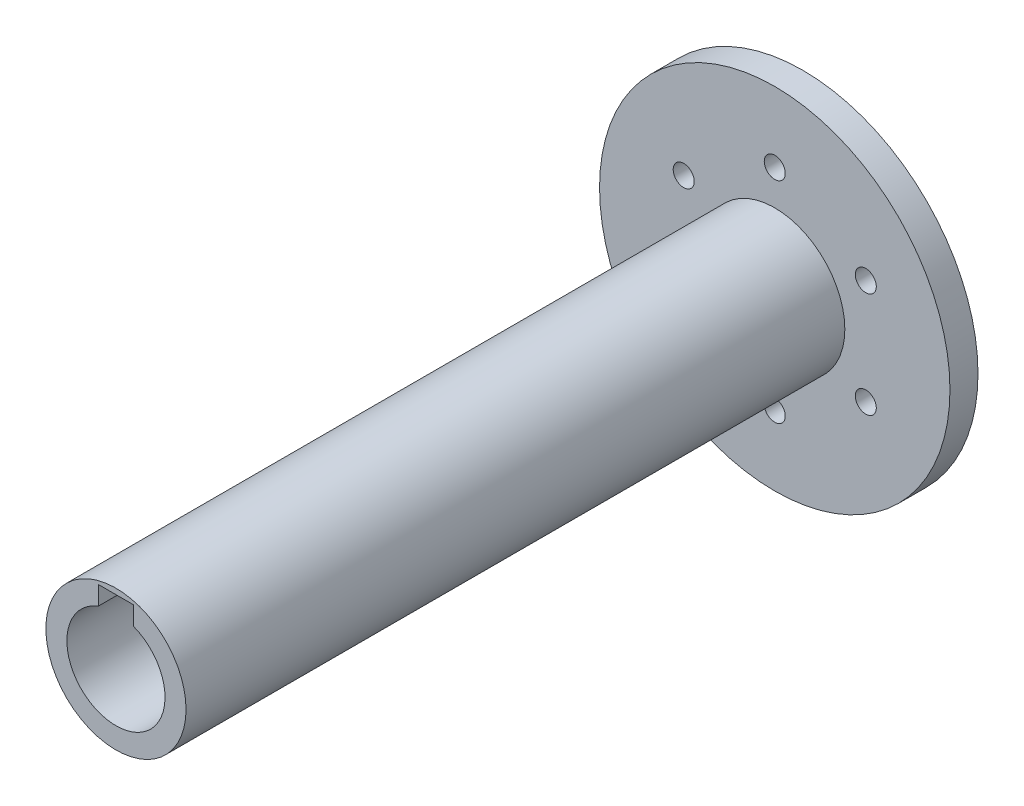
from build123d import *

# Parameters (mm, degrees)
SKETCH_1_R          = 10
EXTRUDE_1_DEPTH     = 94
CUT_EXTRUDE_1_DEPTH = 30
SKETCH_3_R          = 1.5
CUT_EXTRUDE_2_DEPTH = 95
SKETCH_4_R          = 25
SKETCH_4_R_2        = 1.5
EXTRUDE_2_DEPTH     = 4
SKETCH_5_R          = 1.5
CUT_EXTRUDE_5_DEPTH = 4


with BuildPart() as part:
    # 草图1 → 凸台-拉伸1 (new body)
    with BuildSketch(Plane.XY):
        Circle(SKETCH_1_R)
    extrude(amount=EXTRUDE_1_DEPTH)

    # 草图2 → 切除-拉伸1 (cut)
    with BuildSketch(Plane.XY.offset(94)):
        with BuildLine():
            Line((-2.5, 6.538348415), (-2.5, 9.2))
            Line((-2.5, 9.2), (2.5, 9.2))
            Line((2.5, 9.2), (2.5, 6.538348415))
            ThreePointArc((2.5, 6.538348415), (0, -7), (-2.5, 6.538348415))
        make_face()
    extrude(amount=-CUT_EXTRUDE_1_DEPTH, mode=Mode.SUBTRACT)

    # 草图3 → 切除-拉伸2 (cut, through all)
    with BuildSketch(Plane(origin=(0, 0, 0), x_dir=(-1, 0, 0), z_dir=(0, 0, -1))):
        Circle(SKETCH_3_R)
    extrude(amount=-CUT_EXTRUDE_2_DEPTH, mode=Mode.SUBTRACT)

    # 草图4 → 凸台-拉伸2 (add)
    with BuildSketch(Plane(origin=(0, 0, 0), x_dir=(-1, 0, 0), z_dir=(0, 0, -1))):
        Circle(SKETCH_4_R)
        Circle(SKETCH_4_R_2, mode=Mode.SUBTRACT)
    extrude(amount=EXTRUDE_2_DEPTH)

    # 草图5 → 切除-拉伸5 (cut)
    with BuildSketch(Plane(origin=(0, 0, -4), x_dir=(-1, 0, 0), z_dir=(0, 0, -1))):
        with Locations((0, 15)):
            Circle(SKETCH_5_R)
        with Locations((12.990381057, 7.5)):
            Circle(SKETCH_5_R)
        with Locations((12.990381057, -7.5)):
            Circle(SKETCH_5_R)
        with Locations((0, -15)):
            Circle(SKETCH_5_R)
        with Locations((-12.990381057, -7.5)):
            Circle(SKETCH_5_R)
        with Locations((-12.990381057, 7.5)):
            Circle(SKETCH_5_R)
    extrude(amount=-CUT_EXTRUDE_5_DEPTH, mode=Mode.SUBTRACT)


solid = part.part
